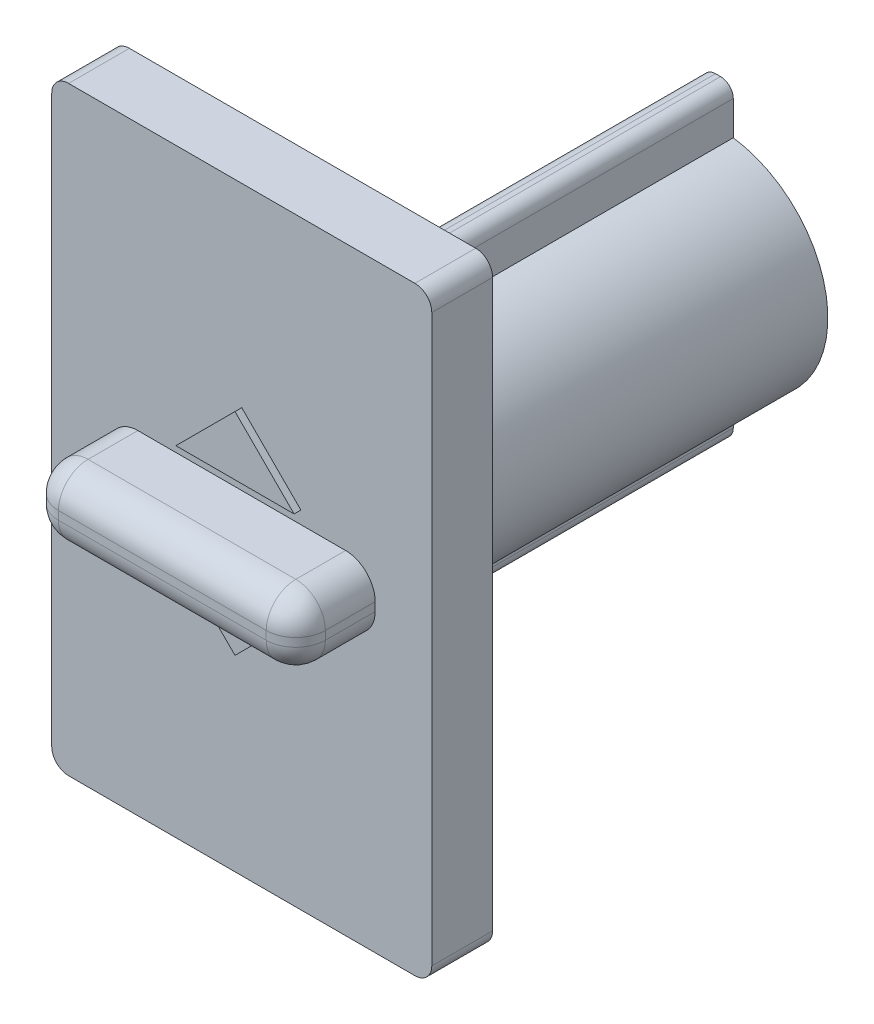
from build123d import *

# Parameters (mm, degrees)
SKETCH1_W           = 35.5
SKETCH1_H           = 22.5
BOSS_EXTRUDE1_DEPTH = 3.6
SKETCH2_W           = 15.8
SKETCH2_H           = 4
BOSS_EXTRUDE2_DEPTH = 4.7
SKETCH3_R           = 6.5
BOSS_EXTRUDE3_DEPTH = 24.6
SKETCH4_W           = 6
SKETCH4_H           = 7.5
CUT_EXTRUDE1_DEPTH  = 16
SKETCH5_W           = 1
SKETCH5_H           = 0.4
SKETCH5_W_2         = 0.4
SKETCH5_H_2         = 1
BOSS_EXTRUDE4_DEPTH = 16
FILLET1_R           = 1
FILLET2_R           = 1.75
BOSS_EXTRUDE5_DEPTH = 0.4
SKETCH7_W           = 1.8
SKETCH7_H           = 5.4
BOSS_EXTRUDE6_DEPTH = 26
FILLET3_R           = 0.75


with BuildPart() as part:
    # Sketch1 → Boss-Extrude1 (new body)
    with BuildSketch(Plane(origin=(0, 0, 0), x_dir=(0, 1, 0), z_dir=(0, 0, 1))):
        Rectangle(SKETCH1_W, SKETCH1_H)
    extrude(amount=BOSS_EXTRUDE1_DEPTH)

    # Sketch2 → Boss-Extrude2 (add)
    with BuildSketch(Plane.XY.offset(3.6)):
        Rectangle(SKETCH2_W, SKETCH2_H)
    extrude(amount=BOSS_EXTRUDE2_DEPTH)

    # Sketch3 → Boss-Extrude3 (add)
    with BuildSketch(Plane(origin=(0, 0, 0), x_dir=(1, 0, 0), z_dir=(0, 0, -1))):
        Circle(SKETCH3_R)
    extrude(amount=BOSS_EXTRUDE3_DEPTH)

    # Sketch4 → Cut-Extrude1 (cut)
    with BuildSketch(Plane(origin=(0, 0, -24.6), x_dir=(1, 0, 0), z_dir=(0, 0, -1))):
        Rectangle(SKETCH4_W, SKETCH4_H)
    extrude(amount=-CUT_EXTRUDE1_DEPTH, mode=Mode.SUBTRACT)

    # Sketch5 → Boss-Extrude4 (add)
    with BuildSketch(Plane(origin=(0, 0, -24.6), x_dir=(-1, 0, 0), z_dir=(0, 0, -1))):
        with Locations((0, 3.75)):
            Rectangle(SKETCH5_W, SKETCH5_H)
        with Locations((-3, 0)):
            Rectangle(SKETCH5_W_2, SKETCH5_H_2)
        with Locations((0, -3.75)):
            Rectangle(SKETCH5_W, SKETCH5_H)
        with Locations((3, 0)):
            Rectangle(SKETCH5_W_2, SKETCH5_H_2)
    extrude(amount=-BOSS_EXTRUDE4_DEPTH)

    # Fillet1
    fillet1_edges = [part.edges().sort_by_distance(p)[0] for p in [
        (11.25, 17.75, 1.8),
        (11.25, -17.75, 1.8),
        (-11.25, -17.75, 1.8),
        (-11.25, 17.75, 1.8),
    ]]
    fillet(fillet1_edges, radius=FILLET1_R)

    # Fillet2
    fillet2_edges = [part.edges().sort_by_distance(p)[0] for p in [
        (7.9, -2, 5.95),
        (7.9, 2, 5.95),
        (-7.9, 2, 5.95),
        (-7.9, -2, 5.95),
        (7.9, 0, 8.3),
        (0, 2, 8.3),
        (-7.9, 0, 8.3),
        (0, -2, 8.3),
    ]]
    fillet(fillet2_edges, radius=FILLET2_R)

    # Sketch6 → Boss-Extrude5 (add)
    with BuildSketch(Plane.XY.offset(3.6)):
        Polygon((3.5, 2.75), (-3.5, 2.75), (0, 6.25), align=None)
        Polygon((3.5, -2.75), (-3.5, -2.75), (0, -6.25), align=None)
    extrude(amount=BOSS_EXTRUDE5_DEPTH)

    # Sketch7 → Boss-Extrude6 (add)
    with BuildSketch(Plane(origin=(0, 0, -24.6), x_dir=(1, 0, 0), z_dir=(0, 0, -1))):
        with Locations((0, 6.5)):
            Rectangle(SKETCH7_W, SKETCH7_H)
        with Locations((0, -6.5)):
            Rectangle(SKETCH7_W, SKETCH7_H)
    extrude(amount=-BOSS_EXTRUDE6_DEPTH)

    # Fillet3
    fillet3_edges = [part.edges().sort_by_distance(p)[0] for p in [
        (0.9, -9.2, -12.3),
        (-0.9, -9.2, -12.3),
        (0.9, 9.2, -12.3),
        (-0.9, 9.2, -12.3),
    ]]
    fillet(fillet3_edges, radius=FILLET3_R)


solid = part.part
